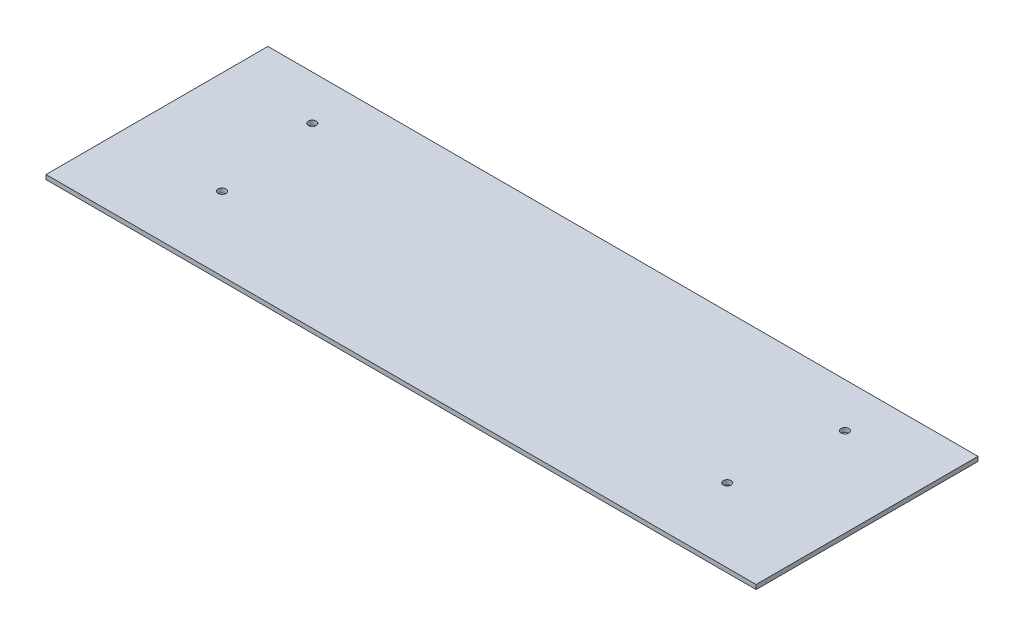
from build123d import *

# Parameters (mm, degrees)
SKETCH1_W           = 406.4
SKETCH1_H           = 127
SKETCH1_R           = 2.25
BOSS_EXTRUDE1_DEPTH = 2.54


with BuildPart() as part:
    # Sketch1 → Boss-Extrude1 (new body)
    with BuildSketch(Plane(origin=(0, 0, 0), x_dir=(1, 0, 0), z_dir=(0, 1, 0))):
        Rectangle(SKETCH1_W, SKETCH1_H)
        with Locations((-152.4, 38.1)):
            Circle(SKETCH1_R, mode=Mode.SUBTRACT)
        with Locations((152.4, 38.1)):
            Circle(SKETCH1_R, mode=Mode.SUBTRACT)
        with Locations((144.568428467, -21.386691682)):
            Circle(SKETCH1_R, mode=Mode.SUBTRACT)
        with Locations((-144.568428467, -21.386691682)):
            Circle(SKETCH1_R, mode=Mode.SUBTRACT)
    extrude(amount=BOSS_EXTRUDE1_DEPTH)


solid = part.part
